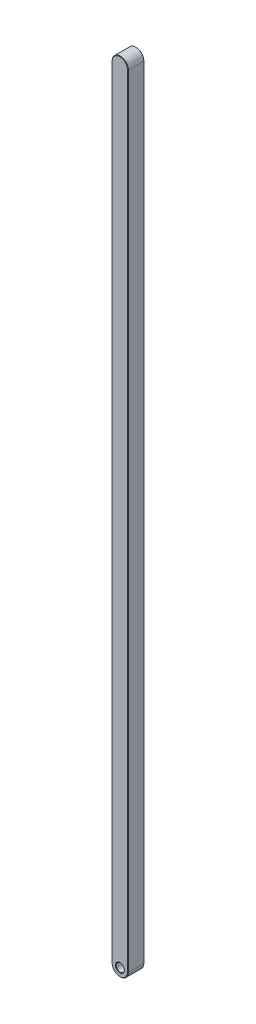
from build123d import *

# Parameters (mm, degrees)
SKETCH1_R           = 2.38125
BOSS_EXTRUDE1_DEPTH = 4.7625
CHAMFER1_SIZE       = 0.254


with BuildPart() as part:
    # Sketch1 → Boss-Extrude1 (new, symmetric)
    with BuildSketch(Plane.XY):
        with BuildLine():
            Line((-4.7625, 0), (-4.7625, 457.2))
            ThreePointArc((-4.7625, 457.2), (0, 461.9625), (4.7625, 457.2))
            Line((4.7625, 457.2), (4.7625, 0))
            ThreePointArc((4.7625, 0), (0, -4.7625), (-4.7625, 0))
        make_face()
        Circle(SKETCH1_R, mode=Mode.SUBTRACT)
    extrude(amount=BOSS_EXTRUDE1_DEPTH, both=True)

    # Chamfer1
    chamfer1_edges = [part.edges().sort_by_distance(p)[0] for p in [
        (-2.38125, 0, -4.7625),
        (4.7625, 228.6, -4.7625),
        (0, 461.9625, -4.7625),
        (-4.7625, 228.6, -4.7625),
        (0, -4.7625, -4.7625),
        (-2.38125, 0, 4.7625),
        (-4.7625, 228.6, 4.7625),
        (0, 461.9625, 4.7625),
        (4.7625, 228.6, 4.7625),
        (0, -4.7625, 4.7625),
    ]]
    chamfer(chamfer1_edges, length=CHAMFER1_SIZE)


solid = part.part
